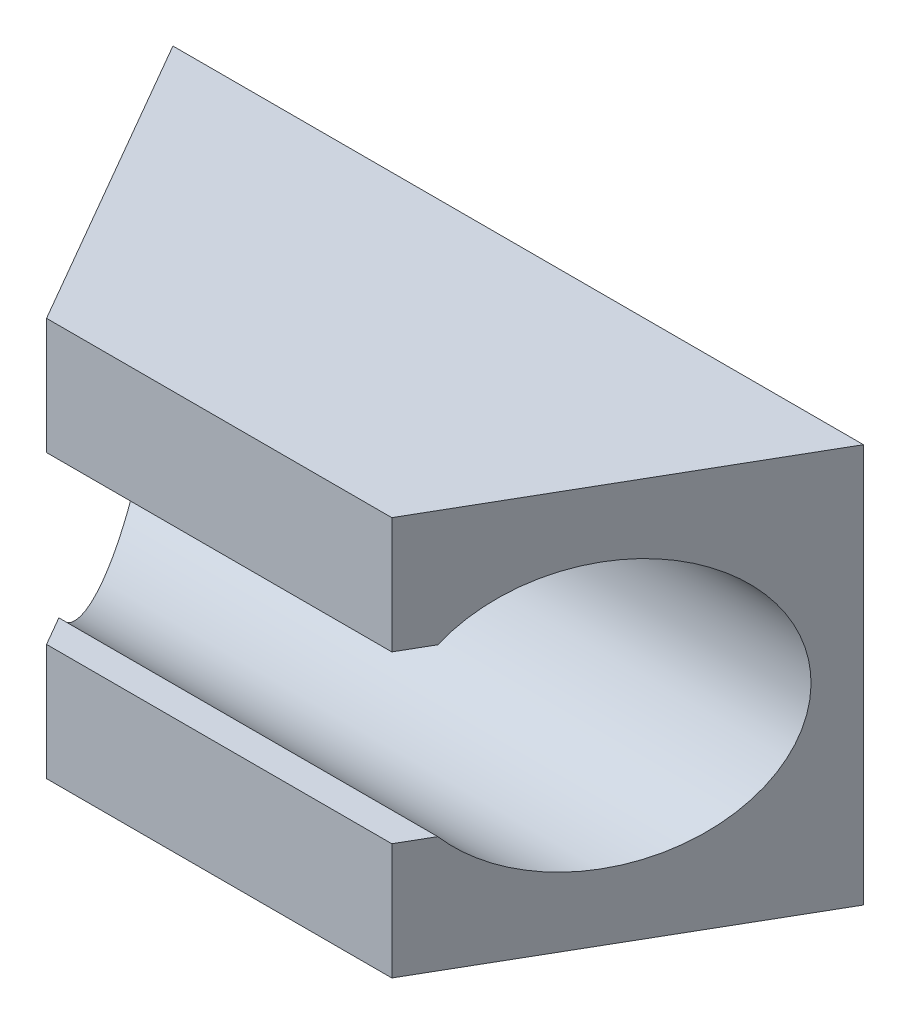
from build123d import *

# Parameters (mm, degrees)
SKETCH8_W           = 10.392304846
SKETCH8_H           = 6
BOSS_EXTRUDE3_DEPTH = 4.5
CUT_EXTRUDE5_DEPTH  = 11.392304845
CUT_EXTRUDE6_DEPTH  = 7


with BuildPart() as part:
    # Sketch8 → Boss-Extrude3 (new body)
    with BuildSketch(Plane.XY):
        Rectangle(SKETCH8_W, SKETCH8_H)
    extrude(amount=BOSS_EXTRUDE3_DEPTH)

    # Sketch9 → Cut-Extrude5 (cut, through all)
    with BuildSketch(Plane(origin=(5.196152423, 0, 0), x_dir=(0, 0, -1), z_dir=(1, 0, 0))):
        with BuildLine():
            Line((-4.0612495, 1.25), (-4.5, 1.25))
            Line((-4.5, 1.25), (-4.5, -1.25))
            Line((-4.5, -1.25), (-4.0612495, -1.25))
            ThreePointArc((-4.0612495, -1.25), (-0.5, 0), (-4.0612495, 1.25))
        make_face()
    extrude(amount=-CUT_EXTRUDE5_DEPTH, mode=Mode.SUBTRACT)

    # Sketch10 → Cut-Extrude6 (cut, through all)
    with BuildSketch(Plane.XZ.offset(3)):
        Polygon((5.196152423, 0), (2.598076211, 4.5), (5.196152423, 4.5), align=None)
        Polygon((-5.196152423, 4.5), (-5.196152423, 0), (-2.598076211, 4.5), align=None)
    extrude(amount=-CUT_EXTRUDE6_DEPTH, mode=Mode.SUBTRACT)


solid = part.part
